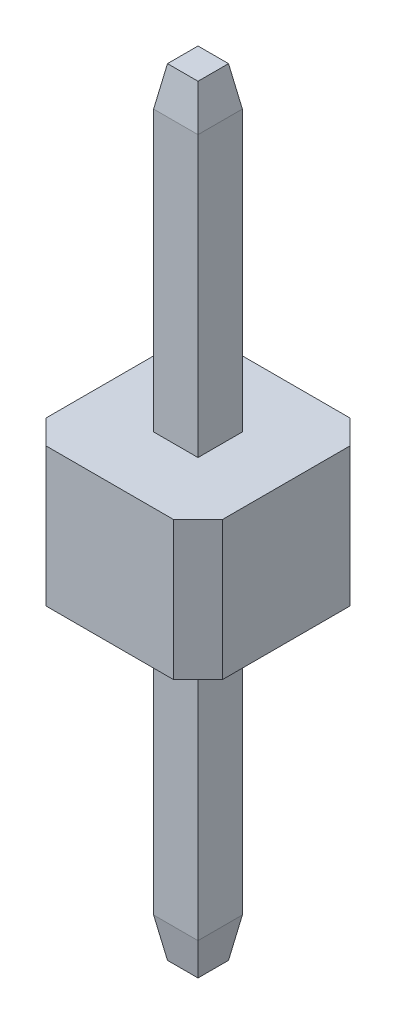
from build123d import *

# Parameters (mm, degrees)
SALIENTE_EXTRUIR1_DEPTH = 1
CROQUIS2_W              = 0.64
CROQUIS2_H              = 0.64
SALIENTE_EXTRUIR2_DEPTH = 5.6
CHAFL_N1_SIZE           = 0.1
CHAFL_N1_SIZE2          = 0.567128182
CHAFL_N1_PART_2_SIZE    = 0.1
CHAFL_N1_PART_2_SIZE2   = 0.567128182


with BuildPart() as part:
    # Croquis1 → Saliente-Extruir1 (new body, symmetric)
    with BuildSketch(Plane(origin=(0, 0, 0), x_dir=(1, 0, 0), z_dir=(0, 1, 0))):
        Polygon((-1.27, 0.92), (-0.92, 1.27), (0.92, 1.27), (1.27, 0.92), (1.27, -0.92), (0.92, -1.27), (-0.92, -1.27), (-1.27, -0.92), align=None)
    extrude(amount=SALIENTE_EXTRUIR1_DEPTH, both=True)

    # Croquis2 → Saliente-Extruir2 (add, symmetric)
    with BuildSketch(Plane(origin=(0, 0, 0), x_dir=(1, 0, 0), z_dir=(0, 1, 0))):
        Rectangle(CROQUIS2_W, CROQUIS2_H)
    extrude(amount=SALIENTE_EXTRUIR2_DEPTH, both=True)

    # Chaflán1
    chafl_n1_edges = [part.edges().sort_by_distance(p)[0] for p in [
        (0.32, -5.6, 0),
        (0, -5.6, -0.32),
        (-0.32, -5.6, 0),
        (0, -5.6, 0.32),
    ]]
    chafl_n1_side = [part.faces().sort_by_distance(p)[0] for p in [
        (0, -5.6, 0),
    ]]
    chamfer(chafl_n1_edges, length=CHAFL_N1_SIZE, length2=CHAFL_N1_SIZE2, reference=chafl_n1_side[0])

    # Chaflán1 part 2
    chafl_n1_part_2_edges = [part.edges().sort_by_distance(p)[0] for p in [
        (0.32, 5.6, 0),
        (0, 5.6, -0.32),
        (-0.32, 5.6, 0),
        (0, 5.6, 0.32),
    ]]
    chafl_n1_part_2_side = [part.faces().sort_by_distance(p)[0] for p in [
        (0, 5.6, 0),
    ]]
    chamfer(chafl_n1_part_2_edges, length=CHAFL_N1_PART_2_SIZE, length2=CHAFL_N1_PART_2_SIZE2, reference=chafl_n1_part_2_side[0])


solid = part.part
